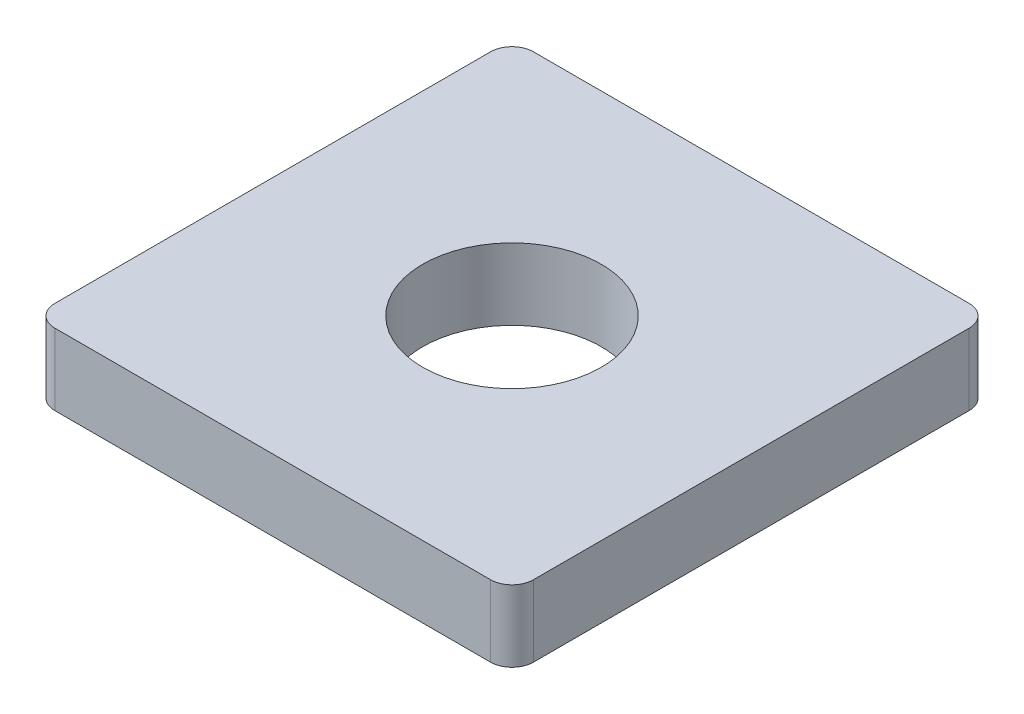
from build123d import *

# Parameters (mm, degrees)
SKETCH1_W             = 6.7
SKETCH1_H             = 6.7
BOSS_EXTRUDE1_DEPTH   = 1
M3X0_5_TAPPED_HOLE1_D = 2.5
FILLET1_R             = 0.3


with BuildPart() as part:
    # Sketch1 → Boss-Extrude1 (new body)
    with BuildSketch(Plane(origin=(0, 0, 0), x_dir=(1, 0, 0), z_dir=(0, 1, 0))):
        Rectangle(SKETCH1_W, SKETCH1_H)
    extrude(amount=BOSS_EXTRUDE1_DEPTH)

    # M3x0.5 Tapped Hole1 (through all)
    with Locations(Plane(origin=(0, 1, 0), x_dir=(1, 0, 0), z_dir=(0, 1, 0))):
        with Locations((0, 0)):
            Hole(M3X0_5_TAPPED_HOLE1_D / 2)

    # Fillet1
    fillet1_edges = [part.edges().sort_by_distance(p)[0] for p in [
        (3.35, 0.5, 3.35),
        (-3.35, 0.5, 3.35),
        (-3.35, 0.5, -3.35),
        (3.35, 0.5, -3.35),
    ]]
    fillet(fillet1_edges, radius=FILLET1_R)


solid = part.part
